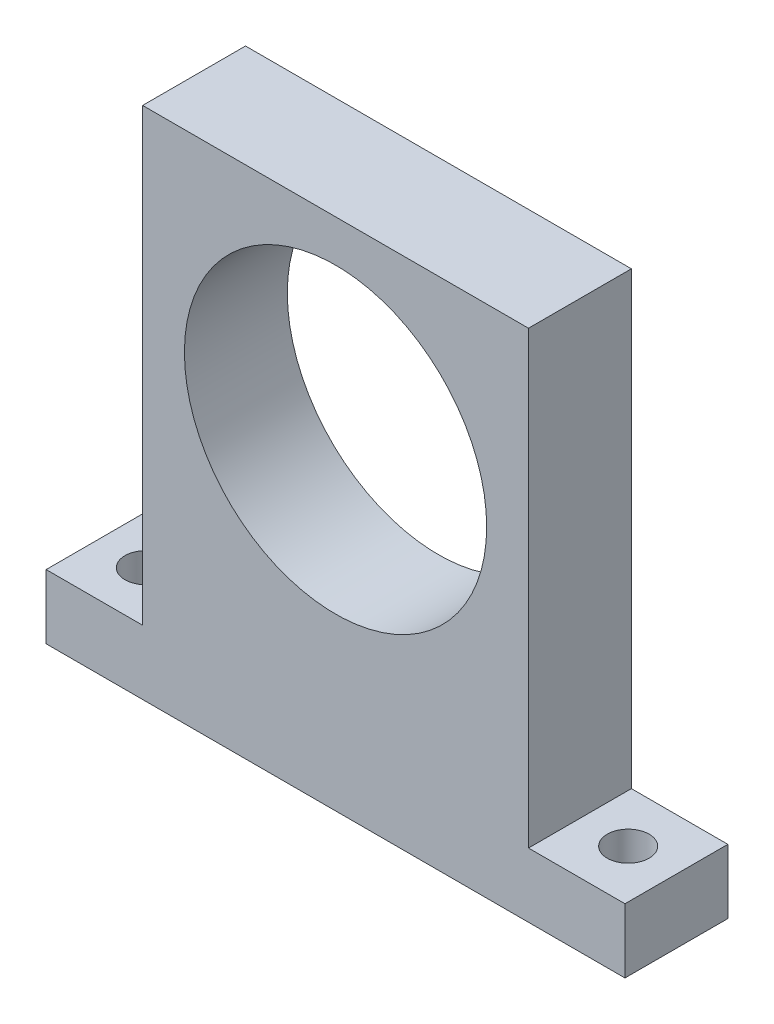
from build123d import *

# Parameters (mm, degrees)
SKETCH1_W           = 60
SKETCH1_H           = 80
SKETCH1_R           = 23.5
BOSS_EXTRUDE1_DEPTH = 8
SKETCH2_W           = 15
SKETCH2_H           = 16
SKETCH2_R           = 3.25
BOSS_EXTRUDE2_DEPTH = 10


with BuildPart() as part:
    # Sketch1 → Boss-Extrude1 (new body, symmetric)
    with BuildSketch(Plane.XY):
        Rectangle(SKETCH1_W, SKETCH1_H)
        with Locations((0, 10)):
            Circle(SKETCH1_R, mode=Mode.SUBTRACT)
    extrude(amount=BOSS_EXTRUDE1_DEPTH, both=True)

    # Sketch2 → Boss-Extrude2 (add)
    with BuildSketch(Plane.XZ.offset(40)):
        with Locations((37.5, 0)):
            Rectangle(SKETCH2_W, SKETCH2_H)
        with Locations((37.5, 0)):
            Circle(SKETCH2_R, mode=Mode.SUBTRACT)
    boss_extrude2 = extrude(amount=-BOSS_EXTRUDE2_DEPTH)

    # Mirror1: Boss-Extrude2 across plane
    add(boss_extrude2.mirror(Plane(origin=(0, 0, 0), x_dir=(0, 0, 1), z_dir=(1, 0, 0))))


solid = part.part
